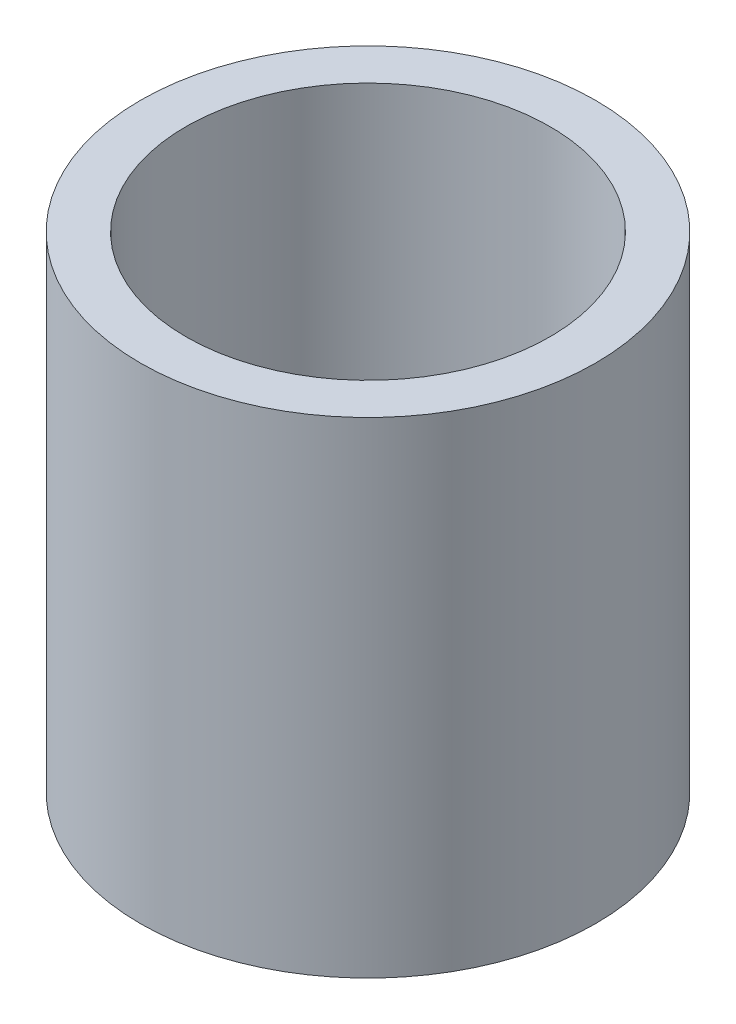
from build123d import *

# Parameters (mm, degrees)
SKETCH1_R           = 11.90625
SKETCH1_R_2         = 9.525
BOSS_EXTRUDE1_DEPTH = 25.4


with BuildPart() as part:
    # Sketch1 → Boss-Extrude1 (new body)
    with BuildSketch(Plane(origin=(0, 0, 0), x_dir=(1, 0, 0), z_dir=(0, 1, 0))):
        Circle(SKETCH1_R)
        Circle(SKETCH1_R_2, mode=Mode.SUBTRACT)
    extrude(amount=BOSS_EXTRUDE1_DEPTH)


solid = part.part
